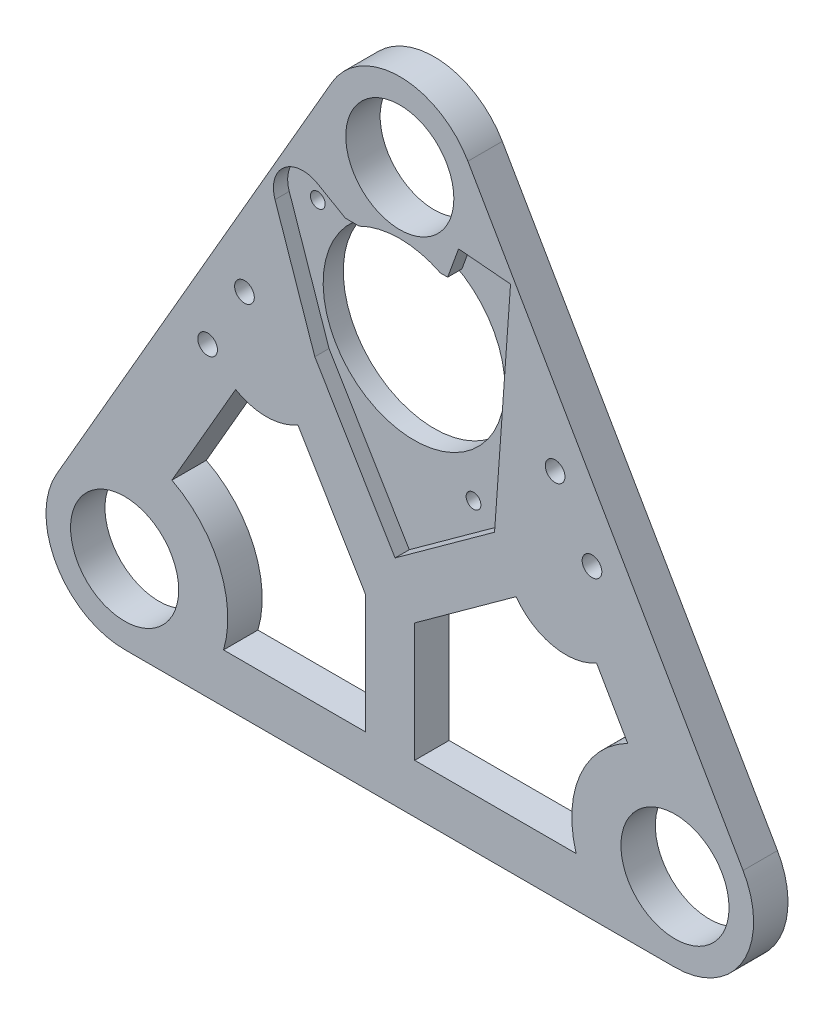
from build123d import *

# Parameters (mm, degrees)
SKETCH1_R           = 11
BOSS_EXTRUDE1_DEPTH = 7
SKETCH3_R           = 18.5
CUT_EXTRUDE1_DEPTH  = 8
CUT_EXTRUDE2_DEPTH  = 2.9
CUT_EXTRUDE3_DEPTH  = 8
SKETCH7_R           = 1.5
CUT_EXTRUDE4_DEPTH  = 5.1
SKETCH10_R          = 2
CUT_EXTRUDE5_DEPTH  = 8


with BuildPart() as part:
    # Sketch1 → Boss-Extrude1 (new body)
    with BuildSketch(Plane.XY):
        with BuildLine():
            Line((42.143593539, 104.994845224), (-13.856406461, 8))
            ThreePointArc((-13.856406461, 8), (-13.856406461, -8), (0, -16))
            Line((0, -16), (112, -16))
            ThreePointArc((112, -16), (125.856406461, -8), (125.856406461, 8))
            Line((125.856406461, 8), (69.856406461, 104.994845224))
            ThreePointArc((69.856406461, 104.994845224), (56, 112.994845224), (42.143593539, 104.994845224))
        make_face()
        Circle(SKETCH1_R, mode=Mode.SUBTRACT)
        with Locations((112, 0)):
            Circle(SKETCH1_R, mode=Mode.SUBTRACT)
        with Locations((56, 96.994845224)):
            Circle(SKETCH1_R, mode=Mode.SUBTRACT)
    extrude(amount=BOSS_EXTRUDE1_DEPTH)

    # Sketch3 → Cut-Extrude1 (cut, through all)
    with BuildSketch(Plane.XY.offset(7)):
        with Locations((56, 65.944845224)):
            Circle(SKETCH3_R)
    extrude(amount=-CUT_EXTRUDE1_DEPTH, mode=Mode.SUBTRACT)

    # Sketch4 → Cut-Extrude2 (cut)
    with BuildSketch(Plane.XY.offset(7)):
        with BuildLine():
            Line((44.91, 82.494845224), (65.74, 82.494845224))
            Line((65.74, 82.494845224), (67.963130932, 88.602847259))
            Line((67.963130932, 88.602847259), (78.535172855, 87.67791344))
            Line((78.535172855, 87.67791344), (75.282447168, 42.324405576))
            Line((75.282447168, 42.324405576), (55.030844768, 27.665872217))
            Line((55.030844768, 27.665872217), (38.701277947, 54.952961607))
            Line((38.701277947, 54.952961607), (30.604248297, 78.605405685))
            ThreePointArc((30.604248297, 78.605405685), (32.46849594, 85.181842037), (39.280834875, 85.744845224))
            Line((39.280834875, 85.744845224), (44.91, 82.494845224))
        make_face()
    extrude(amount=-CUT_EXTRUDE2_DEPTH, mode=Mode.SUBTRACT)

    # Sketch5 → Cut-Extrude3 (cut, through all)
    with BuildSketch(Plane.XY.offset(7)):
        with BuildLine():
            Line((22.59151766, 41.129656408), (9.622063078, 18.665902125))
            ThreePointArc((9.622063078, 18.665902125), (19.321434948, 8.226916285), (20.124611797, -6))
            Line((20.124611797, -6), (49.031546624, -6))
            Line((49.031546624, -6), (49.031546624, 18.216961725))
            Line((49.031546624, 18.216961725), (35.260372543, 41.228916805))
            ThreePointArc((35.260372543, 41.228916805), (28.939452074, 39.455357607), (22.59151766, 41.129656408))
        make_face()
        with BuildLine():
            Line((59.031546624, 18.216961725), (59.031546624, -6))
            Line((59.031546624, -6), (91.875388203, -6))
            ThreePointArc((91.875388203, -6), (92.678565052, 8.226916285), (102.377936922, 18.665902125))
            Line((102.377936922, 18.665902125), (96.035225677, 29.651800259))
            ThreePointArc((96.035225677, 29.651800259), (87.175426517, 28.252595389), (79.659424477, 33.147851127))
            Line((79.659424477, 33.147851127), (59.031546624, 18.216961725))
        make_face()
    extrude(amount=-CUT_EXTRUDE3_DEPTH, mode=Mode.SUBTRACT)

    # Sketch7 → Cut-Extrude4 (cut, through all)
    with BuildSketch(Plane.XY.offset(4.1)):
        with Locations((68.100893251, 42.839462205)):
            Circle(SKETCH7_R)
        with Locations((36.41, 79.994845224)):
            Circle(SKETCH7_R)
    extrude(amount=-CUT_EXTRUDE4_DEPTH, mode=Mode.SUBTRACT)

    # Sketch10 → Cut-Extrude5 (cut, through all)
    with BuildSketch(Plane.XY.offset(7)):
        with Locations((24.388784068, 59.24261314)):
            Circle(SKETCH10_R)
        with Locations((16.888784068, 46.252232084)):
            Circle(SKETCH10_R)
        with Locations((87.611215932, 59.24261314)):
            Circle(SKETCH10_R)
        with Locations((95.111215932, 46.252232084)):
            Circle(SKETCH10_R)
    extrude(amount=-CUT_EXTRUDE5_DEPTH, mode=Mode.SUBTRACT)


solid = part.part
